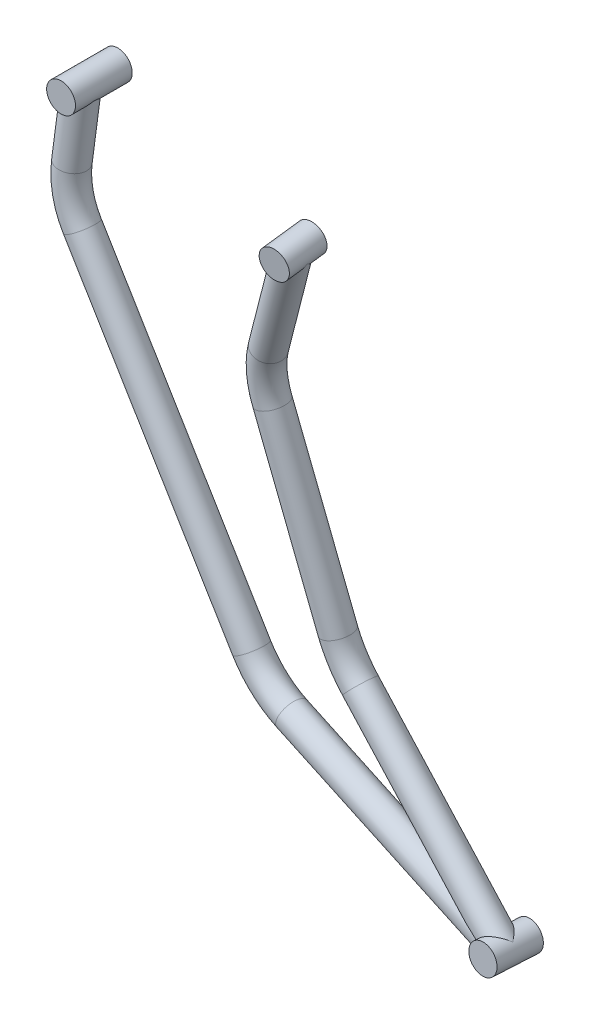
from build123d import *

# Parameters (mm, degrees)
SKETCH2_R           = 12.7
SKETCH3_R           = 12.7
BOSS_EXTRUDE1_DEPTH = 50
SKETCH4_R           = 12.7
BOSS_EXTRUDE2_DEPTH = 35
SKETCH5_R           = 12.7
CUT_EXTRUDE1_DEPTH  = 634.359519319
SKETCH6_R           = 12.7
BOSS_EXTRUDE3_DEPTH = 40


with BuildPart() as part:
    # Sweep1: sweep along a curve in space
    with BuildLine() as sweep1_path:
        Line((-45.263841099, -132.462271612, 42.727197095), (-9.928000519, -34.667527384, 56.556883965))
        ThreePointArc((-45.263841099, -132.462271612, 42.727197095), (-49.367402807, -154.461340148, 40.074170619), (-46.268448436, -176.708192383, 38.254601427))
        Line((1.796645732, -332.656119714, 28.636985574), (-46.268448436, -176.708192383, 38.254601427))
        ThreePointArc((1.796645732, -332.656119714, 28.636985574), (9.693780672, -349.82422739, 28.096448926), (21.793712602, -364.33648604, 28.718411529))
        Line((159.088704017, -490.606286781, 40.497494579), (21.793712602, -364.33648604, 28.718411529))
        Line((159.088704017, -490.606286781, 40.497494579), (-47.055147145, -424.175155849, 20.376642682))
        ThreePointArc((-47.055147145, -424.175155849, 20.376642682), (-68.707848435, -412.682375082, 18.540437025), (-85.12514007, -394.403432402, 17.735499766))
        Line((-85.12514007, -394.403432402, 17.735499766), (-237.067860888, -150.281613827, 14.887673564))
        ThreePointArc((-237.067860888, -150.281613827, 14.887673564), (-245.860225068, -128.979461941, 14.519507014), (-247.259590984, -105.981912067, 13.905207225))
        Line((-247.259590984, -105.981912067, 13.905207225), (-240.877210012, -45.200693371, 12.011549601))
    # Sketch2 → Sweep1 (sweep)
    with BuildSketch(Plane(origin=(-240.877210012, -45.200693371, 12.011549601), x_dir=(0.994511346580908, -0.1045532802574024, -0.003974054509718908), z_dir=(0.10438154847039847, 0.9940550014184, -0.030970090312857718))):
        Circle(SKETCH2_R)
    sweep(path=sweep1_path.line, transition=Transition.RIGHT)

    # Sketch3 → Boss-Extrude1 (add)
    with BuildSketch(Plane(origin=(-240.877210012, -45.200693371, -19.129994659), x_dir=(-1, 0, 0), z_dir=(0, 0, -1))):
        with Locations((-1.013733677, 0)):
            Circle(SKETCH3_R)
    extrude(amount=-BOSS_EXTRUDE1_DEPTH)

    # Sketch4 → Boss-Extrude2 (add)
    with BuildSketch(Plane(origin=(-10.775481352, -33.333297989, 38.894650056), x_dir=(-0.9988573259328992, -0.0035999902794153107, 0.04765587581994679), z_dir=(-0.04779165649125455, 0.07524067855943051, -0.9960194766467865))):
        with Locations(Location((0, 0, 0), (0, 0, 90))):
            Circle(SKETCH4_R)
    extrude(amount=-BOSS_EXTRUDE2_DEPTH)

    # Sketch5 → Cut-Extrude1 (cut, through all)
    with BuildSketch(Plane(origin=(159.570708741, -491.36512975, 17.765263523), x_dir=(-0.9997755298808294, -0.0007068673202907124, -0.021175225857081564), z_dir=(0.02118702082660303, -0.03335573488518622, -0.9992189475278991))):
        Circle(SKETCH5_R)
    extrude(amount=-CUT_EXTRUDE1_DEPTH, mode=Mode.SUBTRACT)


with BuildPart() as body_2:
    # of the pieces the cut leaves, the one that is kept (cut_extrude1_keep)
    add(part.part.solids().sort_by_distance((-228.753597169, -51.353788927, 12.11141185))[0])

    # Sketch6 → Boss-Extrude3 (add)
    with BuildSketch(Plane(origin=(159.570708741, -491.36512975, 17.765263523), x_dir=(-0.9997755298808294, -0.0007068673202907124, -0.021175225857081564), z_dir=(0.02118702082660303, -0.03335573488518622, -0.9992189475278991))):
        with Locations(Location((0, 0, 0), (0, 0, 90))):
            Circle(SKETCH6_R)
    extrude(amount=-BOSS_EXTRUDE3_DEPTH)


solid = body_2.part
